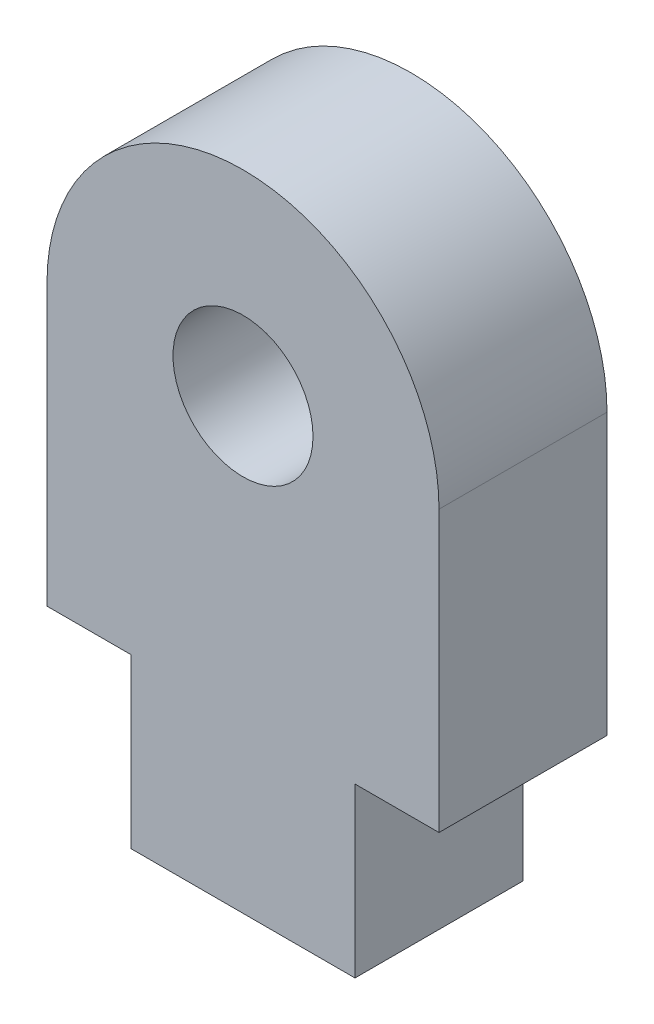
from build123d import *

# Parameters (mm, degrees)
SKETCH1_R           = 1.25
BOSS_EXTRUDE1_DEPTH = 3


with BuildPart() as part:
    # Sketch1 → Boss-Extrude1 (new body)
    with BuildSketch(Plane.XY):
        with BuildLine():
            Line((-3.5, 0), (-3.5, -5))
            Line((-3.5, -5), (-2, -5))
            Line((-2, -5), (-2, -8))
            Line((-2, -8), (2, -8))
            Line((2, -8), (2, -5))
            Line((2, -5), (3.5, -5))
            Line((3.5, -5), (3.5, 0))
            ThreePointArc((3.5, 0), (0, 3.5), (-3.5, 0))
        make_face()
        Circle(SKETCH1_R, mode=Mode.SUBTRACT)
    extrude(amount=BOSS_EXTRUDE1_DEPTH)


solid = part.part
